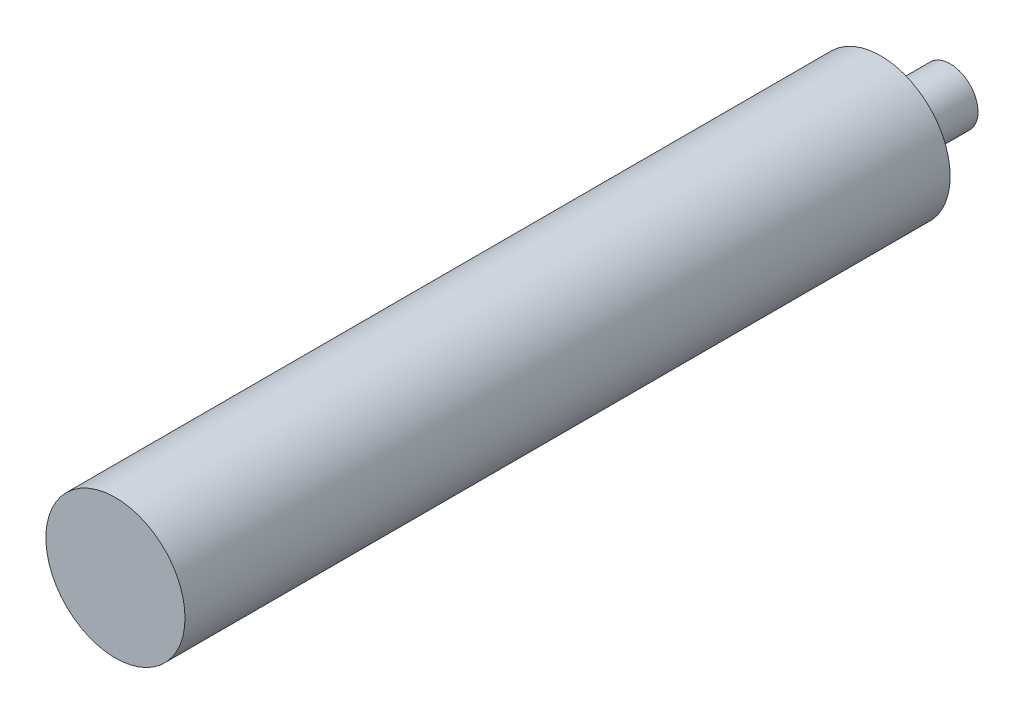
from build123d import *

# Parameters (mm, degrees)
SKETCH1_R           = 2
BOSS_EXTRUDE1_DEPTH = 5
SKETCH2_R           = 5
BOSS_EXTRUDE2_DEPTH = 55


with BuildPart() as part:
    # Sketch1 → Boss-Extrude1 (new body)
    with BuildSketch(Plane.XY):
        Circle(SKETCH1_R)
    extrude(amount=BOSS_EXTRUDE1_DEPTH)

    # Sketch2 → Boss-Extrude2 (add)
    with BuildSketch(Plane.XY.offset(5)):
        Circle(SKETCH2_R)
    extrude(amount=BOSS_EXTRUDE2_DEPTH)


solid = part.part
